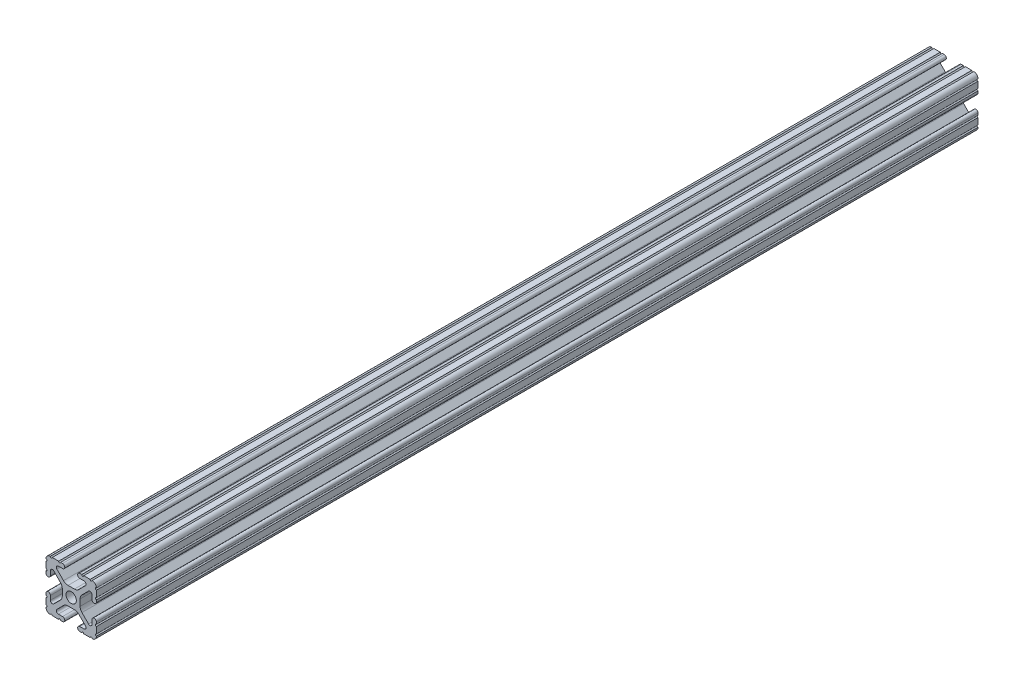
from build123d import *

# Parameters (mm, degrees)
SKETCH1_R           = 2.6035
BOSS_EXTRUDE1_DEPTH = 444.5


with BuildPart() as part:
    # Sketch1 → Boss-Extrude1 (new body)
    with BuildSketch(Plane.XY):
        with BuildLine():
            Line((-12.7, 9.5504), (-12.7, 6.3330836))
            ThreePointArc((-12.7, 6.3330836), (-12.191999975, 5.8250836), (-12.7, 5.3170836))
            Line((-12.7, 5.3170836), (-12.7, 4.3434))
            ThreePointArc((-12.7, 4.3434), (-11.5951, 3.238499971), (-10.4902, 4.3434))
            Line((-10.4902, 4.3434), (-10.4902, 6.474794456))
            ThreePointArc((-10.4902, 6.474794456), (-9.863006367, 7.413456061), (-8.75577951, 7.193214945))
            Line((-8.75577951, 7.193214945), (-5.42573597, 3.863171405))
            ThreePointArc((-5.42573597, 3.863171405), (-4.737482484, 2.833127272), (-4.4958, 1.618107374))
            Line((-4.4958, 1.618107374), (-4.4958, -1.618107374))
            ThreePointArc((-4.4958, -1.618107374), (-4.737482484, -2.833127272), (-5.42573597, -3.863171405))
            Line((-5.42573597, -3.863171405), (-8.75577951, -7.193214945))
            ThreePointArc((-8.75577951, -7.193214945), (-9.863006367, -7.413456061), (-10.4902, -6.474794456))
            Line((-10.4902, -6.474794456), (-10.4902, -4.3434))
            ThreePointArc((-10.4902, -4.3434), (-11.5951, -3.2385), (-12.7, -4.3434))
            Line((-12.7, -4.3434), (-12.7, -5.3170836))
            ThreePointArc((-12.7, -5.3170836), (-12.191999983, -5.8250836), (-12.7, -6.3330836))
            Line((-12.7, -6.3330836), (-12.7, -9.5504))
            ThreePointArc((-12.7, -9.5504), (-12.192000006, -10.058323491), (-12.699846982, -10.566399977))
            ThreePointArc((-12.699846982, -10.566399977), (-12.082522516, -12.082522516), (-10.566399977, -12.699846982))
            ThreePointArc((-10.566399977, -12.699846982), (-10.058323491, -12.192000006), (-9.5504, -12.7))
            Line((-9.5504, -12.7), (-6.3330836, -12.7))
            ThreePointArc((-6.3330836, -12.7), (-5.8250836, -12.191999983), (-5.3170836, -12.7))
            Line((-5.3170836, -12.7), (-4.3434, -12.7))
            ThreePointArc((-4.3434, -12.7), (-3.238499971, -11.5951), (-4.3434, -10.4902))
            Line((-4.3434, -10.4902), (-6.474794456, -10.4902))
            ThreePointArc((-6.474794456, -10.4902), (-7.413456061, -9.863006367), (-7.193214945, -8.75577951))
            Line((-7.193214945, -8.75577951), (-3.863171405, -5.42573597))
            ThreePointArc((-3.863171405, -5.42573597), (-2.833127272, -4.737482484), (-1.618107374, -4.4958))
            Line((-1.618107374, -4.4958), (1.618107374, -4.4958))
            ThreePointArc((1.618107374, -4.4958), (2.833127272, -4.737482484), (3.863171405, -5.42573597))
            Line((3.863171405, -5.42573597), (7.193214945, -8.75577951))
            ThreePointArc((7.193214945, -8.75577951), (7.413456061, -9.863006367), (6.474794456, -10.4902))
            Line((6.474794456, -10.4902), (4.3434, -10.4902))
            ThreePointArc((4.3434, -10.4902), (3.2385, -11.5951), (4.3434, -12.7))
            Line((4.3434, -12.7), (5.3170836, -12.7))
            ThreePointArc((5.3170836, -12.7), (5.8250836, -12.191999983), (6.3330836, -12.7))
            Line((6.3330836, -12.7), (9.5504, -12.7))
            ThreePointArc((9.5504, -12.7), (10.058323491, -12.192000006), (10.566399977, -12.699846982))
            ThreePointArc((10.566399977, -12.699846982), (12.082522516, -12.082522516), (12.699846982, -10.566399977))
            ThreePointArc((12.699846982, -10.566399977), (12.192000006, -10.058323491), (12.7, -9.5504))
            Line((12.7, -9.5504), (12.7, -6.3330836))
            ThreePointArc((12.7, -6.3330836), (12.191999983, -5.8250836), (12.7, -5.3170836))
            Line((12.7, -5.3170836), (12.7, -4.3434))
            ThreePointArc((12.7, -4.3434), (11.5951, -3.238499971), (10.4902, -4.3434))
            Line((10.4902, -4.3434), (10.4902, -6.474794456))
            ThreePointArc((10.4902, -6.474794456), (9.863006367, -7.413456061), (8.75577951, -7.193214945))
            Line((8.75577951, -7.193214945), (5.42573597, -3.863171405))
            ThreePointArc((5.42573597, -3.863171405), (4.737482484, -2.833127272), (4.4958, -1.618107374))
            Line((4.4958, -1.618107374), (4.4958, 1.618107374))
            ThreePointArc((4.4958, 1.618107374), (4.737482484, 2.833127272), (5.42573597, 3.863171405))
            Line((5.42573597, 3.863171405), (8.75577951, 7.193214945))
            ThreePointArc((8.75577951, 7.193214945), (9.863006367, 7.413456061), (10.4902, 6.474794456))
            Line((10.4902, 6.474794456), (10.4902, 4.3434))
            ThreePointArc((10.4902, 4.3434), (11.5951, 3.2385), (12.7, 4.3434))
            Line((12.7, 4.3434), (12.7, 5.3170836))
            ThreePointArc((12.7, 5.3170836), (12.191999983, 5.8250836), (12.7, 6.3330836))
            Line((12.7, 6.3330836), (12.7, 9.5504))
            ThreePointArc((12.7, 9.5504), (12.192000006, 10.058323491), (12.699846982, 10.566399977))
            ThreePointArc((12.699846982, 10.566399977), (12.082522516, 12.082522516), (10.566399977, 12.699846982))
            ThreePointArc((10.566399977, 12.699846982), (10.058323491, 12.192000006), (9.5504, 12.7))
            Line((9.5504, 12.7), (6.3330836, 12.7))
            ThreePointArc((6.3330836, 12.7), (5.8250836, 12.192), (5.3170836, 12.7))
            Line((5.3170836, 12.7), (4.3434, 12.7))
            ThreePointArc((4.3434, 12.7), (3.238499971, 11.5951), (4.3434, 10.4902))
            Line((4.3434, 10.4902), (6.474794456, 10.4902))
            ThreePointArc((6.474794456, 10.4902), (7.413456061, 9.863006367), (7.193214945, 8.75577951))
            Line((7.193214945, 8.75577951), (3.863171405, 5.42573597))
            ThreePointArc((3.863171405, 5.42573597), (2.833127272, 4.737482484), (1.618107374, 4.4958))
            Line((1.618107374, 4.4958), (-1.618107374, 4.4958))
            ThreePointArc((-1.618107374, 4.4958), (-2.833127272, 4.737482484), (-3.863171405, 5.42573597))
            Line((-3.863171405, 5.42573597), (-7.193214945, 8.75577951))
            ThreePointArc((-7.193214945, 8.75577951), (-7.413456061, 9.863006367), (-6.474794456, 10.4902))
            Line((-6.474794456, 10.4902), (-4.3434, 10.4902))
            ThreePointArc((-4.3434, 10.4902), (-3.2385, 11.5951), (-4.3434, 12.7))
            Line((-4.3434, 12.7), (-5.3170836, 12.7))
            ThreePointArc((-5.3170836, 12.7), (-5.8250836, 12.191999983), (-6.3330836, 12.7))
            Line((-6.3330836, 12.7), (-9.5504, 12.7))
            ThreePointArc((-9.5504, 12.7), (-10.058323491, 12.192000006), (-10.566399977, 12.699846982))
            ThreePointArc((-10.566399977, 12.699846982), (-12.082522516, 12.082522516), (-12.699846982, 10.566399977))
            ThreePointArc((-12.699846982, 10.566399977), (-12.192000006, 10.058323491), (-12.7, 9.5504))
        make_face()
        Circle(SKETCH1_R, mode=Mode.SUBTRACT)
    extrude(amount=-BOSS_EXTRUDE1_DEPTH)


solid = part.part
